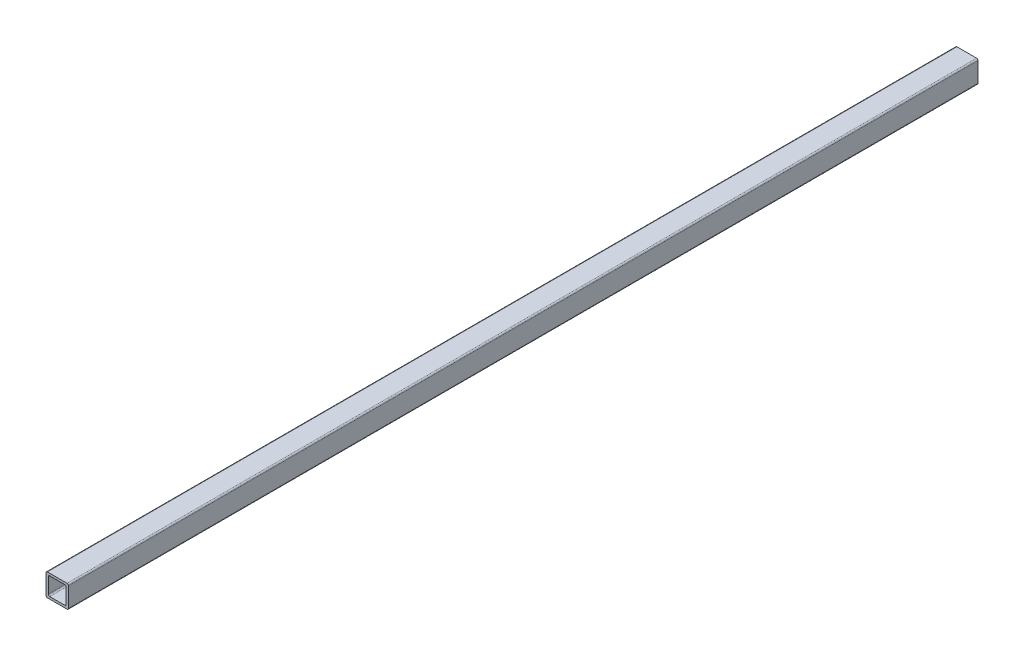
from build123d import *

# Parameters (mm, degrees)
SKETCH1_W           = 7.9
SKETCH1_H           = 7.9
SKETCH1_W_2         = 6.3
SKETCH1_H_2         = 6.3
BOSS_EXTRUDE1_DEPTH = 320
FILLET1_R           = 0.5


with BuildPart() as part:
    # Sketch1 → Boss-Extrude1 (new body)
    with BuildSketch(Plane.XY):
        Rectangle(SKETCH1_W, SKETCH1_H)
        Rectangle(SKETCH1_W_2, SKETCH1_H_2, mode=Mode.SUBTRACT)
    extrude(amount=BOSS_EXTRUDE1_DEPTH)

    # Fillet1
    fillet1_edges = [part.edges().sort_by_distance(p)[0] for p in [
        (-3.15, 3.15, 160),
        (-3.15, -3.15, 160),
        (3.15, -3.15, 160),
        (3.15, 3.15, 160),
        (-3.95, 3.95, 160),
        (3.95, 3.95, 160),
        (3.95, -3.95, 160),
        (-3.95, -3.95, 160),
    ]]
    fillet(fillet1_edges, radius=FILLET1_R)


solid = part.part
